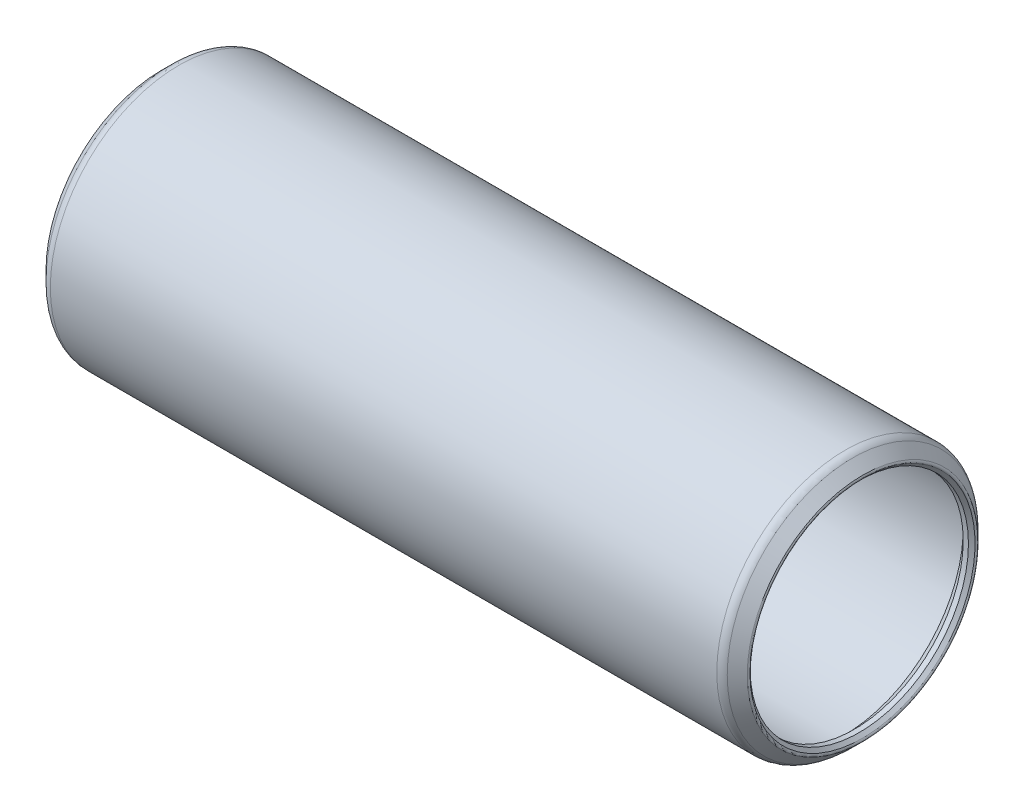
from build123d import *


with BuildPart() as part:
    # Sketch1 → Revolve1 (revolve)
    with BuildSketch(Plane.XY):
        with BuildLine():
            Line((-0.517960245, 6.836210245), (-0.3175, 6.63575))
            Line((-0.3175, 6.63575), (0, 6.63575))
            Line((0, 6.63575), (0.635, 7.27075))
            Line((0.635, 7.27075), (40.9702, 7.27075))
            Line((40.9702, 7.27075), (41.6052, 6.63575))
            Line((41.6052, 6.63575), (41.9227, 6.63575))
            Line((41.9227, 6.63575), (42.123160245, 6.836210245))
            ThreePointArc((42.123160245, 6.836210245), (42.160357684, 6.926012806), (42.123160245, 7.015815367))
            Line((42.123160245, 7.015815367), (41.514462806, 7.624512806))
            ThreePointArc((41.514462806, 7.624512806), (41.30845398, 7.762163503), (41.06545, 7.8105))
            Line((41.06545, 7.8105), (0.53975, 7.8105))
            ThreePointArc((0.53975, 7.8105), (0.29674602, 7.762163503), (0.090737194, 7.624512806))
            Line((0.090737194, 7.624512806), (-0.517960245, 7.015815367))
            ThreePointArc((-0.517960245, 7.015815367), (-0.555157684, 6.926012806), (-0.517960245, 6.836210245))
        make_face()
    revolve(axis=Axis((41.6052, 0, 0), (-1, 0, 0)))


solid = part.part
